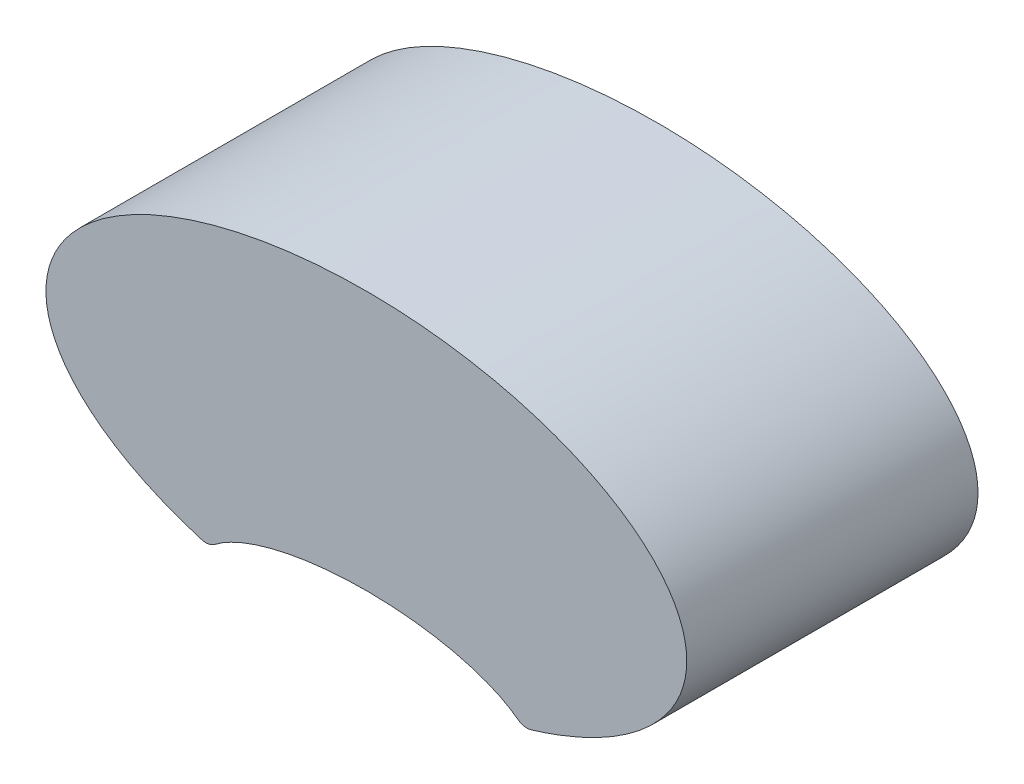
from build123d import *

# Parameters (mm, degrees)
SALIENTE_EXTRUIR2_DEPTH = 1
SALIENTE_EXTRUIR4_DEPTH = 1
CORTAR_EXTRUIR5_DEPTH   = 10


with BuildPart() as part:
    # Croquis2 → Saliente-Extruir2 (new body)
    with BuildSketch(Plane.XY):
        with BuildLine():
            Line((1.575601287, 0.305798808), (1.451356133, 0.305798808))
            ThreePointArc((1.451356133, 0.305798808), (1.42488117, 0.311210102), (1.402652914, 0.326575985))
            add(Edge.make_bspline(
                [(1.402652914, 0.326575985), (1.360130432, 0.370928794), (1.273091339, 0.474573616), (1.405822435, 0.509874509), (1.5, 0.687275792)],
                knots=[0.042799464, 0.042799464, 0.042799464, 0.042799464, 0.330664192, 1, 1, 1, 1], degree=3))
            ThreePointArc((1.5, 0.687275792), (1.516652539, 0.777416177), (1.478603287, 0.860811923))
            ThreePointArc((1.478603287, 0.860811923), (1.417548585, 0.910292451), (1.344234138, 0.938594237))
            ThreePointArc((1.344234138, 0.938594237), (1.329383947, 0.944391303), (1.317113195, 0.954567884))
            ThreePointArc((1.317113195, 0.954567884), (0, 1.552634988), (-1.317113195, 0.954567884))
            ThreePointArc((-1.317113195, 0.954567884), (-1.329383947, 0.944391303), (-1.344234138, 0.938594237))
            ThreePointArc((-1.344234138, 0.938594237), (-1.417548585, 0.910292451), (-1.478603287, 0.860811923))
            ThreePointArc((-1.478603287, 0.860811923), (-1.516652539, 0.777416177), (-1.5, 0.687275792))
            add(Edge.make_bspline(
                [(-1.402652914, 0.326575985), (-1.360130432, 0.370928794), (-1.273091339, 0.474573616), (-1.405822435, 0.509874509), (-1.5, 0.687275792)],
                knots=[0.042799464, 0.042799464, 0.042799464, 0.042799464, 0.330664192, 1, 1, 1, 1], degree=3))
            ThreePointArc((-1.402652914, 0.326575985), (-1.42488117, 0.311210102), (-1.451356133, 0.305798808))
            Line((-1.451356133, 0.305798808), (-1.575601287, 0.305798808))
            ThreePointArc((-1.575601287, 0.305798808), (-1.660882273, 0.220517823), (-1.575601287, 0.135236837))
            Line((-1.575601287, 0.135236837), (-1.303551262, 0.135236837))
            add(Edge.make_bspline(
                [(-1.303551262, 0.135236837), (-1.104083131, 0.023402954), (-0.904615, 0.135236837)],
                knots=[3.859431567, 3.859431567, 3.859431567, 5.565346393, 5.565346393, 5.565346393], degree=2, weights=[1, 0.657758416, 1]))
            Line((-0.904615, 0.135236837), (-0.535294671, 0.135236837))
            add(Edge.make_bspline(
                [(-0.535294671, 0.135236837), (0, -0.349692637), (0.535294671, 0.135236837)],
                knots=[3.538676333, 3.538676333, 3.538676333, 5.886101627, 5.886101627, 5.886101627], degree=2, weights=[1, 0.386730581, 1]))
            Line((0.535294671, 0.135236837), (0.904615, 0.135236837))
            add(Edge.make_bspline(
                [(0.904615, 0.135236837), (1.104083131, 0.023402954), (1.303551262, 0.135236837)],
                knots=[0.717838914, 0.717838914, 0.717838914, 2.42375374, 2.42375374, 2.42375374], degree=2, weights=[1, 0.657758416, 1]))
            Line((1.303551262, 0.135236837), (1.575601287, 0.135236837))
            ThreePointArc((1.575601287, 0.135236837), (1.660882273, 0.220517823), (1.575601287, 0.305798808))
        make_face()
        with BuildLine():
            ThreePointArc((-0.565338465, 0.309855878), (-0.541919045, 0.308582711), (-0.520495625, 0.318128772))
            add(Edge.make_bspline(
                [(0.520495625, 0.318128772), (0, 0.718700768), (-0.520495625, 0.318128772)],
                knots=[0.458545425, 0.458545425, 0.458545425, 2.683047228, 2.683047228, 2.683047228], degree=2, weights=[1, 0.442644262, 1]))
            ThreePointArc((0.520495625, 0.318128772), (0.541919045, 0.308582711), (0.565338465, 0.309855878))
            add(Edge.make_bspline(
                [(0.565338465, 0.309855878), (3.976320062, 1.331658914), (0, 1.331658914), (-3.976320062, 1.331658914), (-0.565338465, 0.309855878)],
                knots=[5.252165222, 5.252165222, 5.252165222, 7.853981634, 7.853981634, 10.455798046, 10.455798046, 10.455798046], degree=2, weights=[1, 0.266623609, 1, 0.266623609, 1]))
        make_face(mode=Mode.SUBTRACT)
    extrude(amount=-SALIENTE_EXTRUIR2_DEPTH)

    # Croquis6 → Cortar-Extruir5 (cut)
    with BuildSketch(Plane.XY):
        with BuildLine():
            Line((0.535294671, 0.135236837), (0.904615, 0.135236837))
            add(Edge.make_bspline(
                [(0.904615, 0.135236837), (1.104083131, 0.023402954), (1.303551262, 0.135236837)],
                knots=[0.717838914, 0.717838914, 0.717838914, 2.42375374, 2.42375374, 2.42375374], degree=2, weights=[1, 0.657758416, 1]))
            Line((1.303551262, 0.135236837), (1.575601287, 0.135236837))
            ThreePointArc((1.575601287, 0.135236837), (1.660882273, 0.220517823), (1.575601287, 0.305798808))
            Line((1.575601287, 0.305798808), (1.451356133, 0.305798808))
            ThreePointArc((1.451356133, 0.305798808), (1.42488117, 0.311210102), (1.402652914, 0.326575985))
            add(Edge.make_bspline(
                [(1.402652914, 0.326575985), (1.360130432, 0.370928794), (1.273091339, 0.474573616), (1.405822435, 0.509874509), (1.5, 0.687275792)],
                knots=[0.042799464, 0.042799464, 0.042799464, 0.042799464, 0.330664192, 1, 1, 1, 1], degree=3))
            ThreePointArc((1.5, 0.687275792), (1.516652539, 0.777416177), (1.478603287, 0.860811923))
            ThreePointArc((1.478603287, 0.860811923), (1.417548585, 0.910292451), (1.344234138, 0.938594237))
            ThreePointArc((1.344234138, 0.938594237), (1.329383947, 0.944391303), (1.317113195, 0.954567884))
            ThreePointArc((1.317113195, 0.954567884), (0, 1.552634988), (-1.317113195, 0.954567884))
            ThreePointArc((-1.317113195, 0.954567884), (-1.329383947, 0.944391303), (-1.344234138, 0.938594237))
            ThreePointArc((-1.344234138, 0.938594237), (-1.417548585, 0.910292451), (-1.478603287, 0.860811923))
            ThreePointArc((-1.478603287, 0.860811923), (-1.516652539, 0.777416177), (-1.5, 0.687275792))
            add(Edge.make_bspline(
                [(-1.5, 0.687275792), (-1.405822435, 0.509874509), (-1.273091339, 0.474573616), (-1.360130432, 0.370928794), (-1.402652914, 0.326575985)],
                knots=[0.042799464, 0.042799464, 0.042799464, 0.042799464, 0.712135272, 1, 1, 1, 1], degree=3))
            ThreePointArc((-1.402652914, 0.326575985), (-1.42488117, 0.311210102), (-1.451356133, 0.305798808))
            Line((-1.451356133, 0.305798808), (-1.575601287, 0.305798808))
            ThreePointArc((-1.575601287, 0.305798808), (-1.660882273, 0.220517823), (-1.575601287, 0.135236837))
            Line((-1.575601287, 0.135236837), (-1.303551262, 0.135236837))
            add(Edge.make_bspline(
                [(-1.303551262, 0.135236837), (-1.104083131, 0.023402954), (-0.904615, 0.135236837)],
                knots=[3.859431567, 3.859431567, 3.859431567, 5.565346393, 5.565346393, 5.565346393], degree=2, weights=[1, 0.657758416, 1]))
            Line((-0.904615, 0.135236837), (-0.535294671, 0.135236837))
            add(Edge.make_bspline(
                [(-0.535294671, 0.135236837), (0, -0.349692637), (0.535294671, 0.135236837)],
                knots=[3.538676333, 3.538676333, 3.538676333, 5.886101627, 5.886101627, 5.886101627], degree=2, weights=[1, 0.386730581, 1]))
        make_face()
        with BuildLine():
            ThreePointArc((0.520495625, 0.318128772), (0.541919045, 0.308582711), (0.565338465, 0.309855878))
            add(Edge.make_bspline(
                [(0.565338465, 0.309855878), (3.976320062, 1.331658914), (0, 1.331658914), (-3.976320062, 1.331658914), (-0.565338465, 0.309855878)],
                knots=[5.252165222, 5.252165222, 5.252165222, 7.853981634, 7.853981634, 10.455798046, 10.455798046, 10.455798046], degree=2, weights=[1, 0.266623609, 1, 0.266623609, 1]))
            ThreePointArc((-0.565338465, 0.309855878), (-0.541919045, 0.308582711), (-0.520495625, 0.318128772))
            add(Edge.make_bspline(
                [(0.520495625, 0.318128772), (0, 0.718700768), (-0.520495625, 0.318128772)],
                knots=[0.458545425, 0.458545425, 0.458545425, 2.683047228, 2.683047228, 2.683047228], degree=2, weights=[1, 0.442644262, 1]))
        make_face(mode=Mode.SUBTRACT)
    extrude(amount=-CORTAR_EXTRUIR5_DEPTH, mode=Mode.SUBTRACT)


with BuildPart() as body_2:
    # Croquis5 → Saliente-Extruir4 (new body)
    with BuildSketch(Plane.XY):
        with BuildLine():
            ThreePointArc((0.520495625, 0.318128772), (0.541919045, 0.308582711), (0.565338465, 0.309855878))
            add(Edge.make_bspline(
                [(0.565338465, 0.309855878), (3.976320062, 1.331658914), (0, 1.331658914), (-3.976320062, 1.331658914), (-0.565338465, 0.309855878)],
                knots=[5.252165222, 5.252165222, 5.252165222, 7.853981634, 7.853981634, 10.455798046, 10.455798046, 10.455798046], degree=2, weights=[1, 0.266623609, 1, 0.266623609, 1]))
            ThreePointArc((-0.565338465, 0.309855878), (-0.541919045, 0.308582711), (-0.520495625, 0.318128772))
            add(Edge.make_bspline(
                [(0.520495625, 0.318128772), (0, 0.718700768), (-0.520495625, 0.318128772)],
                knots=[0.458545425, 0.458545425, 0.458545425, 2.683047228, 2.683047228, 2.683047228], degree=2, weights=[1, 0.442644262, 1]))
        make_face()
    extrude(amount=-SALIENTE_EXTRUIR4_DEPTH)


solid = body_2.part
